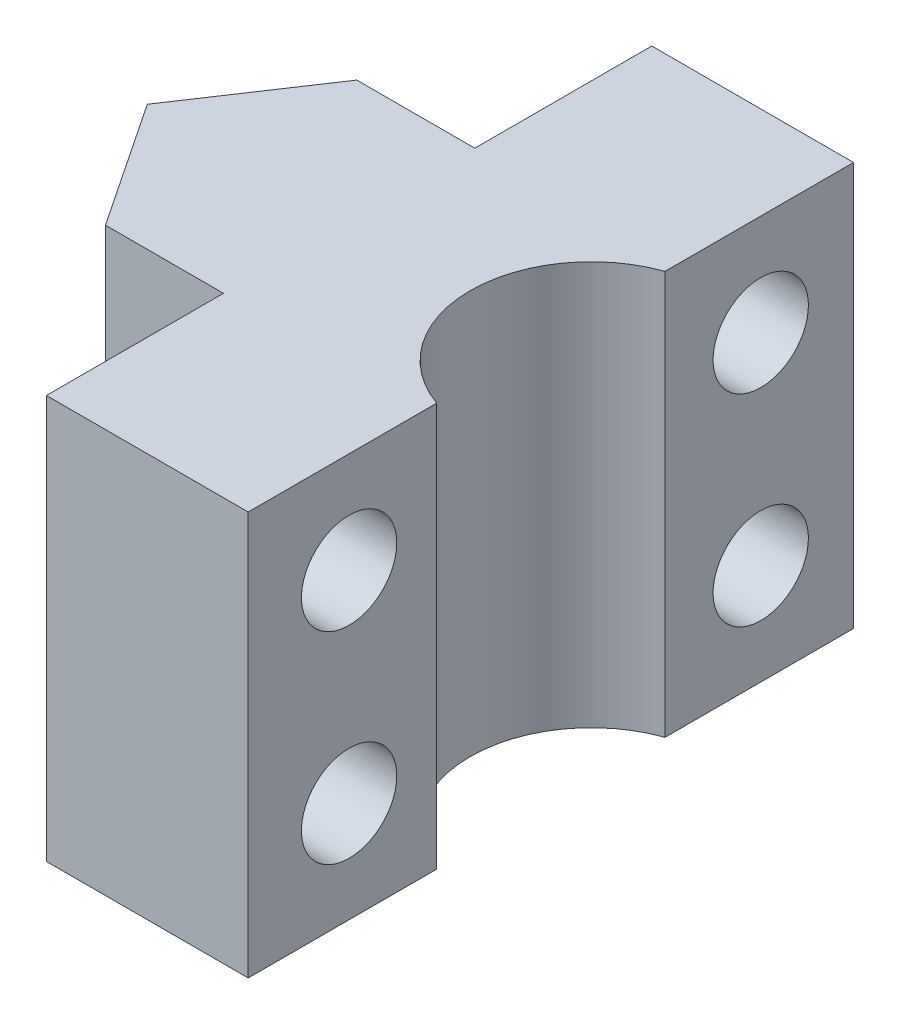
from build123d import *

# Parameters (mm, degrees)
SKETCH1_W           = 12.7
SKETCH1_H           = 19.05
BOSS_EXTRUDE1_DEPTH = 12.7
CUT_EXTRUDE2_DEPTH  = 12.7
SKETCH5_R           = 1.5
CUT_EXTRUDE3_DEPTH  = 12.7
CUT_EXTRUDE4_DEPTH  = 12.7


with BuildPart() as part:
    # Sketch1 → Boss-Extrude1 (new body)
    with BuildSketch(Plane(origin=(0, 0, 0), x_dir=(1, 0, 0), z_dir=(0, 1, 0))):
        with Locations((6.35, 9.525)):
            Rectangle(SKETCH1_W, SKETCH1_H)
    extrude(amount=BOSS_EXTRUDE1_DEPTH)

    # Sketch4 → Cut-Extrude2 (cut)
    with BuildSketch(Plane(origin=(0, 12.7, 0), x_dir=(1, 0, 0), z_dir=(0, 1, 0))):
        Polygon((0, 19.05), (0, 9.525), (6.35, 19.05), align=None)
        Polygon((6.35, 0), (0, 9.525), (0, 0), align=None)
        with BuildLine():
            Line((12.7, 5.932897552), (12.7, 13.117102448))
            ThreePointArc((12.7, 13.117102448), (10.16, 9.525), (12.7, 5.932897552))
        make_face()
        with BuildLine():
            ThreePointArc((17.78, 9.525), (16.169704526, 12.635851973), (12.7, 13.117102448))
            Line((12.7, 13.117102448), (12.7, 5.932897552))
            ThreePointArc((12.7, 5.932897552), (16.169704526, 6.414148027), (17.78, 9.525))
        make_face()
    extrude(amount=-CUT_EXTRUDE2_DEPTH, mode=Mode.SUBTRACT)

    # Sketch5 → Cut-Extrude3 (cut)
    with BuildSketch(Plane(origin=(12.7, 0, 0), x_dir=(0, 0, -1), z_dir=(1, 0, 0))):
        with Locations((3.175, 9.525)):
            Circle(SKETCH5_R)
        with Locations((16.129, 9.525)):
            Circle(SKETCH5_R)
        with Locations((16.129, 3.175)):
            Circle(SKETCH5_R)
        with Locations((3.175, 3.175)):
            Circle(SKETCH5_R)
    extrude(amount=-CUT_EXTRUDE3_DEPTH, mode=Mode.SUBTRACT)

    # Sketch6 → Cut-Extrude4 (cut)
    with BuildSketch(Plane.XZ):
        Polygon((6.35, 0), (6.35, -5.570300529), (2.636466314, -5.570300529), align=None)
    cut_extrude4 = extrude(amount=-CUT_EXTRUDE4_DEPTH, mode=Mode.SUBTRACT)

    # Mirror1: Cut-Extrude4 across plane
    add(cut_extrude4.mirror(Plane(origin=(0, 0, -9.525), x_dir=(1, 0, 0), z_dir=(0, 0, -1))), mode=Mode.SUBTRACT)


solid = part.part
